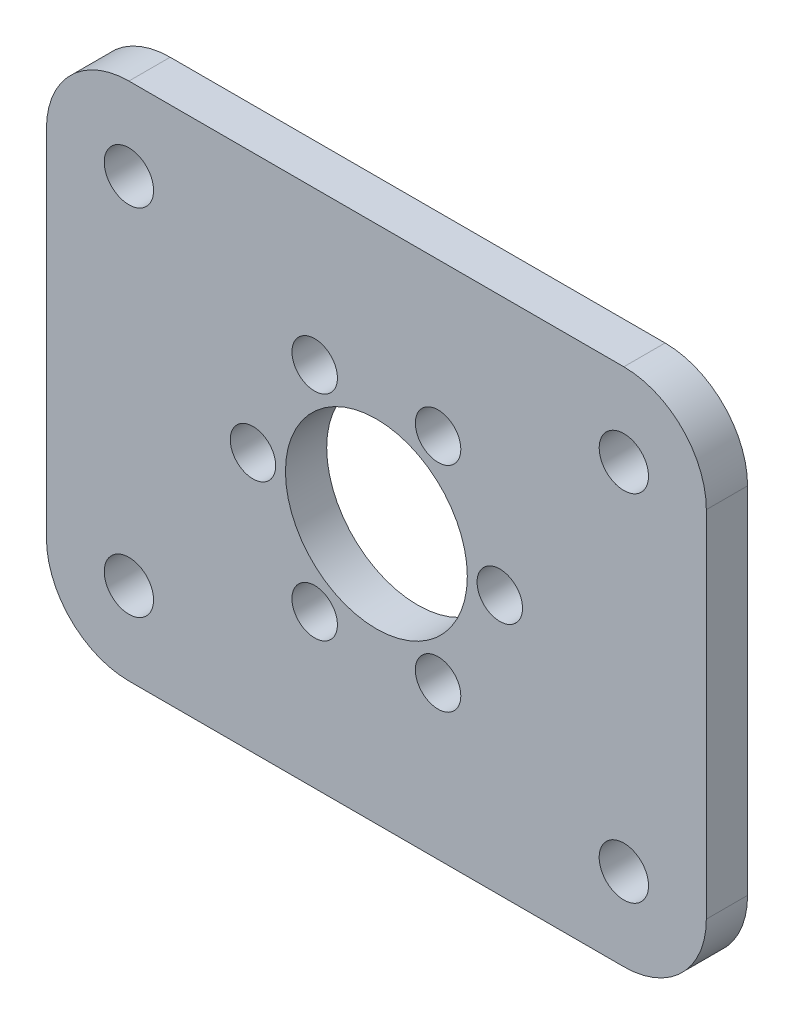
from build123d import *

# Parameters (mm, degrees)
SKETCH1_W           = 50.8
SKETCH1_H           = 40
SKETCH1_R           = 7
BOSS_EXTRUDE1_DEPTH = 3.175
FILLET1_R           = 6.35
SKETCH9_R           = 1.75
M3_THROUGH_DEPTH    = 4.175
SKETCH10_R          = 1.89865
CUT_EXTRUDE2_DEPTH  = 4.175


with BuildPart() as part:
    # Sketch1 → Boss-Extrude1 (new body)
    with BuildSketch(Plane.XY):
        Rectangle(SKETCH1_W, SKETCH1_H)
        Circle(SKETCH1_R, mode=Mode.SUBTRACT)
    extrude(amount=BOSS_EXTRUDE1_DEPTH)

    # Fillet1
    fillet1_edges = [part.edges().sort_by_distance(p)[0] for p in [
        (-25.4, 20, 1.5875),
        (25.4, 20, 1.5875),
        (25.4, -20, 1.5875),
        (-25.4, -20, 1.5875),
    ]]
    fillet(fillet1_edges, radius=FILLET1_R)

    # Sketch9 → M3-through (cut, through all)
    with BuildSketch(Plane.XY.offset(3.175)):
        with Locations((9.5, 0)):
            Circle(SKETCH9_R)
        with Locations((4.75, -8.227241336)):
            Circle(SKETCH9_R)
        with Locations((-4.75, -8.227241336)):
            Circle(SKETCH9_R)
        with Locations((-9.5, 0)):
            Circle(SKETCH9_R)
        with Locations((-4.75, 8.227241336)):
            Circle(SKETCH9_R)
        with Locations((4.75, 8.227241336)):
            Circle(SKETCH9_R)
    extrude(amount=-M3_THROUGH_DEPTH, mode=Mode.SUBTRACT)

    # Sketch10 → Cut-Extrude2 (cut, through all)
    with BuildSketch(Plane.XY.offset(3.175)):
        with Locations((19.05, -13.65)):
            Circle(SKETCH10_R)
        with Locations((19.05, 13.65)):
            Circle(SKETCH10_R)
        with Locations((-19.05, -13.65)):
            Circle(SKETCH10_R)
        with Locations((-19.05, 13.65)):
            Circle(SKETCH10_R)
    extrude(amount=-CUT_EXTRUDE2_DEPTH, mode=Mode.SUBTRACT)


solid = part.part
